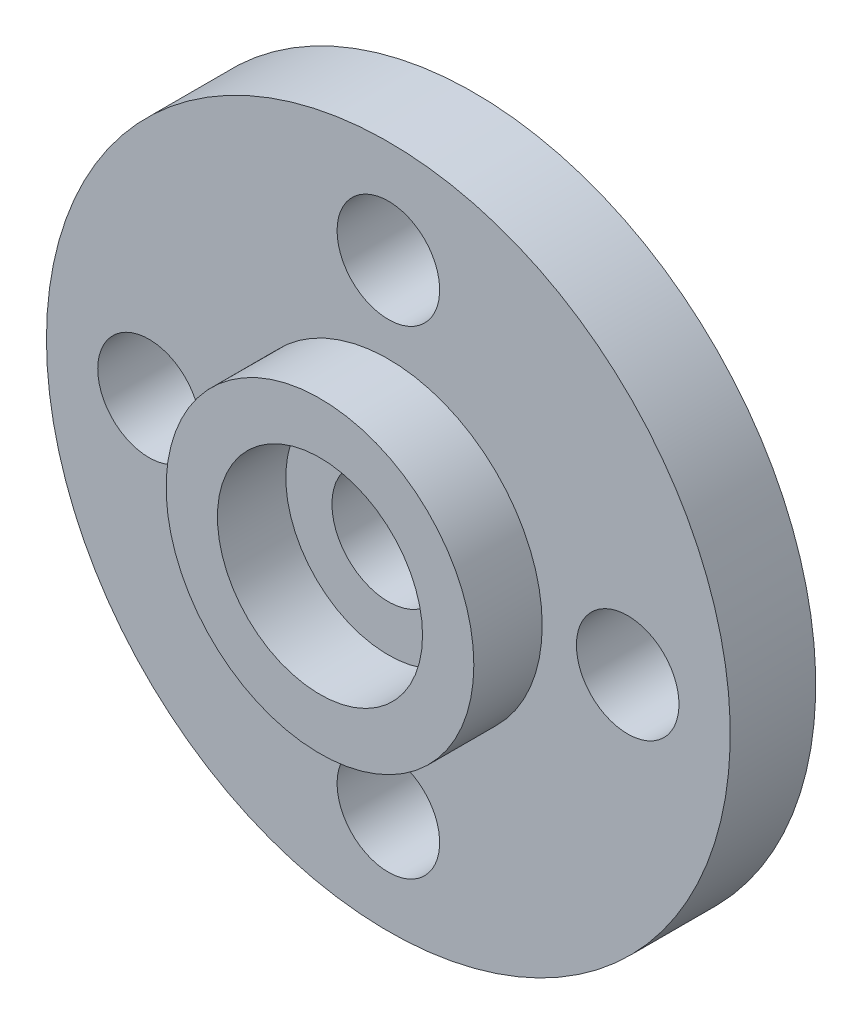
from build123d import *

# Parameters (mm, degrees)
SKETCH_1_R          = 4.5
SKETCH_1_R_2        = 3
EXTRUDE_1_DEPTH     = 2
SKETCH_2_R          = 10
SKETCH_2_R_2        = 1.65
EXTRUDE_2_DEPTH     = 2.5
SKETCH_3_R          = 1.5
CUT_EXTRUDE_1_DEPTH = 2.5


with BuildPart() as part:
    # 草图1 → 凸台-拉伸1 (new body)
    with BuildSketch(Plane.XY):
        Circle(SKETCH_1_R)
        Circle(SKETCH_1_R_2, mode=Mode.SUBTRACT)
    extrude(amount=EXTRUDE_1_DEPTH)

    # 草图2 → 凸台-拉伸2 (add)
    with BuildSketch(Plane(origin=(0, 0, 0), x_dir=(-1, 0, 0), z_dir=(0, 0, -1))):
        Circle(SKETCH_2_R)
        Circle(SKETCH_2_R_2, mode=Mode.SUBTRACT)
    extrude(amount=EXTRUDE_2_DEPTH)

    # 草图3 → 切除-拉伸1 (cut)
    with BuildSketch(Plane(origin=(0, 0, -2.5), x_dir=(-1, 0, 0), z_dir=(0, 0, -1))):
        with Locations((7, 0)):
            Circle(SKETCH_3_R)
        with Locations((0, -7)):
            Circle(SKETCH_3_R)
        with Locations((-7, 0)):
            Circle(SKETCH_3_R)
        with Locations((0, 7)):
            Circle(SKETCH_3_R)
    extrude(amount=-CUT_EXTRUDE_1_DEPTH, mode=Mode.SUBTRACT)


solid = part.part
